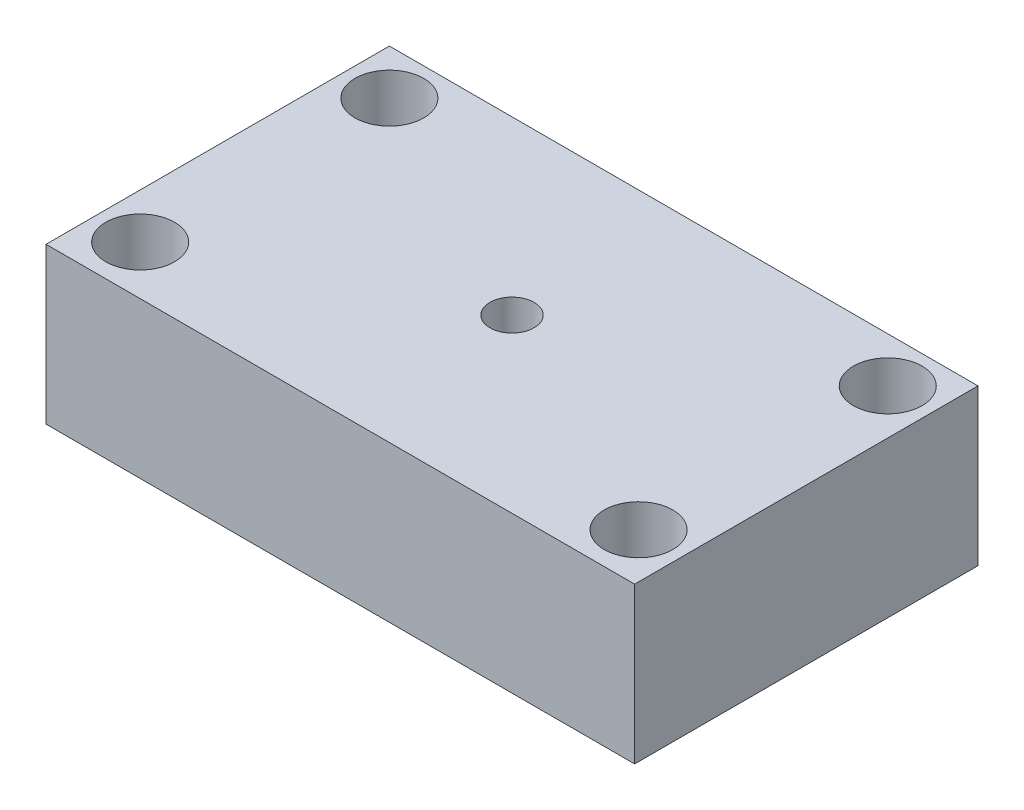
from build123d import *

# Parameters (mm, degrees)
SKETCH1_W           = 60
SKETCH1_H           = 35
SKETCH1_R           = 3.5
SKETCH1_R_2         = 2.25
BOSS_EXTRUDE1_DEPTH = 15.875


with BuildPart() as part:
    # Sketch1 → Boss-Extrude1 (new body)
    with BuildSketch(Plane(origin=(0, 0, 0), x_dir=(1, 0, 0), z_dir=(0, 1, 0))):
        with Locations((30, 17.5)):
            Rectangle(SKETCH1_W, SKETCH1_H)
        with Locations((4.6, 30.4)):
            Circle(SKETCH1_R, mode=Mode.SUBTRACT)
        with Locations((55.4, 30.4)):
            Circle(SKETCH1_R, mode=Mode.SUBTRACT)
        with Locations((4.6, 5)):
            Circle(SKETCH1_R, mode=Mode.SUBTRACT)
        with Locations((55.4, 5)):
            Circle(SKETCH1_R, mode=Mode.SUBTRACT)
        with Locations((30, 17.5)):
            Circle(SKETCH1_R_2, mode=Mode.SUBTRACT)
    extrude(amount=BOSS_EXTRUDE1_DEPTH)


solid = part.part
